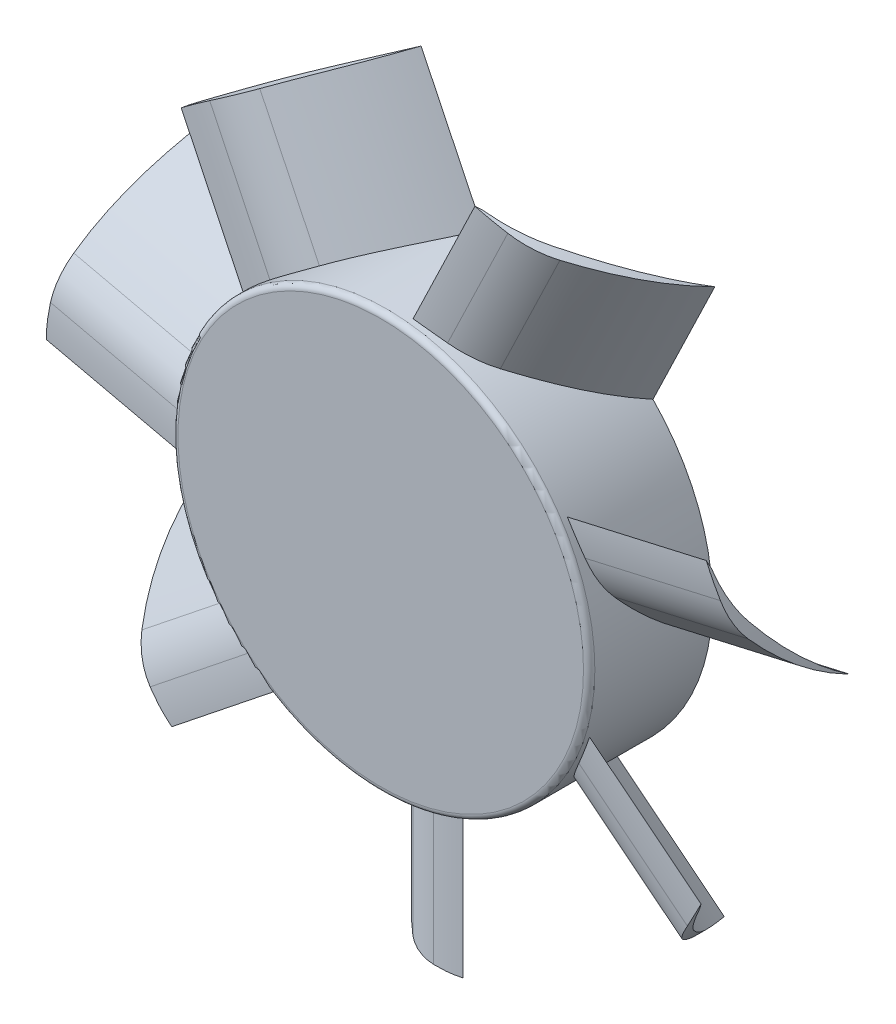
from build123d import *

# Parameters (mm, degrees)
SKETCH_1_R               = 11
EXTRUDE_1_DEPTH          = 6.5
SKETCH_2_R               = 9.75
CUT_EXTRUDE_1_DEPTH      = 5.5
SKETCH_3_R               = 0.7
EXTRUDE_2_DEPTH          = 7.5
CHAMFER_1_SIZE           = 0.6
EXTRUDE_START            = -10
EXTRUDE_3_DEPTH          = 23
PATTERN_CIRCULAR_1_COUNT = 7
FILLET_1_R               = 0.3
SKETCH_5_OUTSIDE_W       = 86.532
SKETCH_5_OUTSIDE_H       = 84.877
SKETCH_5_OUTSIDE_R       = 18.25
CUT_EXTRUDE_2_DEPTH      = 23


with BuildPart() as part:
    # Эскиз1 → Бобышка-Вытянуть1 (new body)
    with BuildSketch(Plane.XY):
        Circle(SKETCH_1_R)
    extrude(amount=EXTRUDE_1_DEPTH)

    # Эскиз2 → Вырез-Вытянуть1 (cut)
    with BuildSketch(Plane(origin=(0, 0, 0), x_dir=(-1, 0, 0), z_dir=(0, 0, -1))):
        Circle(SKETCH_2_R)
    extrude(amount=-CUT_EXTRUDE_1_DEPTH, mode=Mode.SUBTRACT)

    # Эскиз3 → Бобышка-Вытянуть2 (add)
    with BuildSketch(Plane(origin=(0, 0, 5.5), x_dir=(-1, 0, 0), z_dir=(0, 0, -1))):
        Circle(SKETCH_3_R)
    extrude(amount=EXTRUDE_2_DEPTH)

    # Фаска1
    chamfer_1_edges = [part.edges().sort_by_distance(p)[0] for p in [
        (0.7, 0, -2),
    ]]
    chamfer(chamfer_1_edges, length=CHAMFER_1_SIZE)

    # Эскиз4 → Бобышка-Вытянуть3 (add)
    with BuildSketch(Plane(origin=(0, 0, 0), x_dir=(1, 0, 0), z_dir=(0, 1, 0)).offset(EXTRUDE_START)):
        with BuildLine():
            ThreePointArc((3.75, -5.9), (2.910954768, -5.877455841), (2.076425924, -5.787640746))
            ThreePointArc((2.076425924, -5.787640746), (1.016898237, -5.476222818), (0.082906283, -4.886952865))
            ThreePointArc((0.082906283, -4.886952865), (-2.084101368, -2.63998988), (-3.75, 0))
            ThreePointArc((-3.75, 0), (-1.712075741, -2.552424329), (0.739315837, -4.710822941))
            ThreePointArc((0.739315837, -4.710822941), (2.002660979, -5.416468702), (3.40130611, -5.787640746))
            ThreePointArc((3.40130611, -5.787640746), (3.575082247, -5.845591808), (3.75, -5.9))
        make_face()
    extrude_3 = extrude(amount=-EXTRUDE_3_DEPTH)

    # Круговой массив1: Бобышка-Вытянуть3 ×7 about axis
    pattern_circular_1_axis = Axis((0, 0, 6.5), (0, 0, -1))
    for i in range(1, PATTERN_CIRCULAR_1_COUNT):
        add(extrude_3.rotate(pattern_circular_1_axis, i * 360 / PATTERN_CIRCULAR_1_COUNT))

    # Скругление1
    fillet_1_edges = [part.edges().sort_by_distance(p)[0] for p in [
        (-11, 0, 6.5),
    ]]
    fillet(fillet_1_edges, radius=FILLET_1_R)

    # Эскиз5 outside → Вырез-Вытянуть2 (cut)
    with BuildSketch(Plane.XY.offset(6.5)):
        with Locations((0, -0.8205)):
            Rectangle(SKETCH_5_OUTSIDE_W, SKETCH_5_OUTSIDE_H)
        Circle(SKETCH_5_OUTSIDE_R, mode=Mode.SUBTRACT)
    extrude(amount=-CUT_EXTRUDE_2_DEPTH, mode=Mode.SUBTRACT)


solid = part.part
